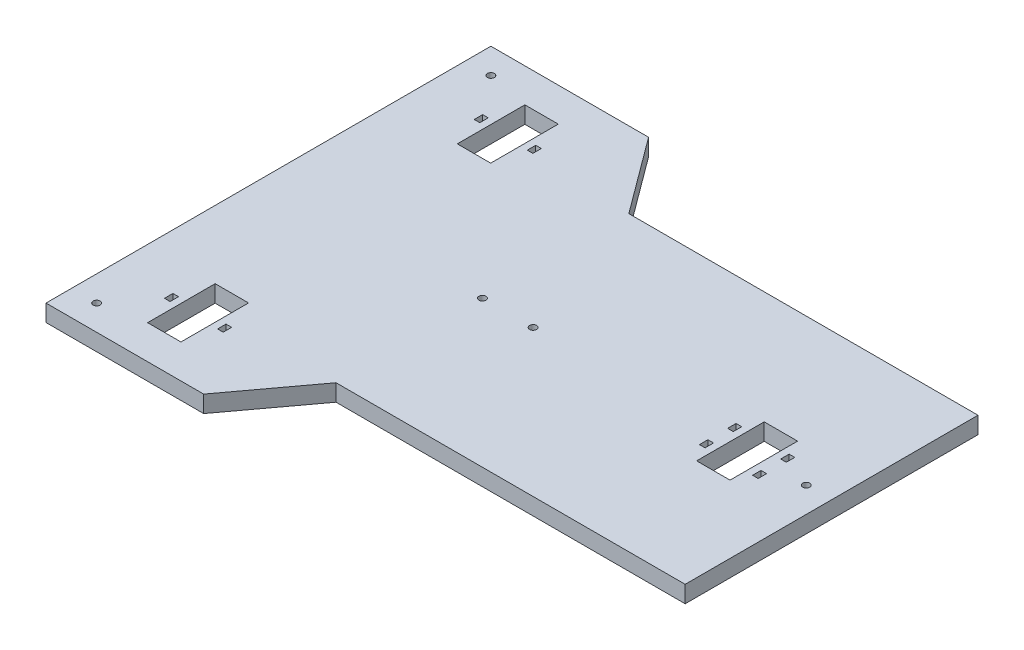
from build123d import *

# Parameters (mm, degrees)
ESQUISSE1_W          = 2
ESQUISSE1_H          = 3
ESQUISSE1_W_2        = 11.857650871
ESQUISSE1_H_2        = 24
ESQUISSE1_W_3        = 11.857650872
BOSS_EXTRU_1_DEPTH   = 6
D_GAGEMENT_M2_51_D   = 2.5
D_GAGEMENT_M31_D     = 3.25
D_GAGEMENT_M31_DEPTH = 4


with BuildPart() as part:
    # Esquisse1 → Boss.-Extru.1 (new body)
    with BuildSketch(Plane(origin=(0, 0, 0), x_dir=(1, 0, 0), z_dir=(0, 1, 0))):
        Polygon((200.65431579, 26.883578947), (200.65431579, 130.883578947), (76.654558535, 130.883578947), (56.654558535, 157.883578947), (0.654315789, 157.883578947), (0.654315789, -0.116421053), (56.654558535, -0.116421053), (76.654558535, 26.883578947), align=None)
        with Locations((21.225574277, 133.883578948)):
            Rectangle(ESQUISSE1_W, ESQUISSE1_H, mode=Mode.SUBTRACT)
        with Locations((40.083225148, 133.883578948)):
            Rectangle(ESQUISSE1_W, ESQUISSE1_H, mode=Mode.SUBTRACT)
        with Locations((21.225574277, 23.883578948)):
            Rectangle(ESQUISSE1_W, ESQUISSE1_H, mode=Mode.SUBTRACT)
        with Locations((40.083225148, 23.883578948)):
            Rectangle(ESQUISSE1_W, ESQUISSE1_H, mode=Mode.SUBTRACT)
        with Locations((161.22557428, 73.883578947)):
            Rectangle(ESQUISSE1_W, ESQUISSE1_H, mode=Mode.SUBTRACT)
        with Locations((180.083225144, 83.883578947)):
            Rectangle(ESQUISSE1_W, ESQUISSE1_H, mode=Mode.SUBTRACT)
        with Locations((30.654399713, 133.883578948)):
            Rectangle(ESQUISSE1_W_2, ESQUISSE1_H_2, mode=Mode.SUBTRACT)
        with Locations((30.654399713, 23.883578948)):
            Rectangle(ESQUISSE1_W_2, ESQUISSE1_H_2, mode=Mode.SUBTRACT)
        with Locations((170.654399716, 78.883578947)):
            Rectangle(ESQUISSE1_W_3, ESQUISSE1_H_2, mode=Mode.SUBTRACT)
        with Locations((180.083225144, 73.883578947)):
            Rectangle(ESQUISSE1_W, ESQUISSE1_H, mode=Mode.SUBTRACT)
        with Locations((161.22557428, 83.883578947)):
            Rectangle(ESQUISSE1_W, ESQUISSE1_H, mode=Mode.SUBTRACT)
    extrude(amount=BOSS_EXTRU_1_DEPTH)

    # Dégagement M2.51 (through all)
    with Locations(Plane(origin=(0, 6, 0), x_dir=(1, 0, 0), z_dir=(0, 1, 0))):
        with Locations((9.654315789, 148.883578947), (9.654315789, 8.883578947), (76.654315789, 78.883578947), (94.65431579, 78.883578947), (191.65431579, 78.883578947)):
            Hole(D_GAGEMENT_M2_51_D / 2)

    # Dégagement M31
    with Locations(Plane(origin=(0, 0, 0), x_dir=(-1, 0, 0), z_dir=(0, -1, 0))):
        with Locations((-191.65431579, 78.883578947), (-9.654315789, 8.883578947), (-9.654315789, 148.883578947)):
            Hole(D_GAGEMENT_M31_D / 2, depth=D_GAGEMENT_M31_DEPTH)


solid = part.part
